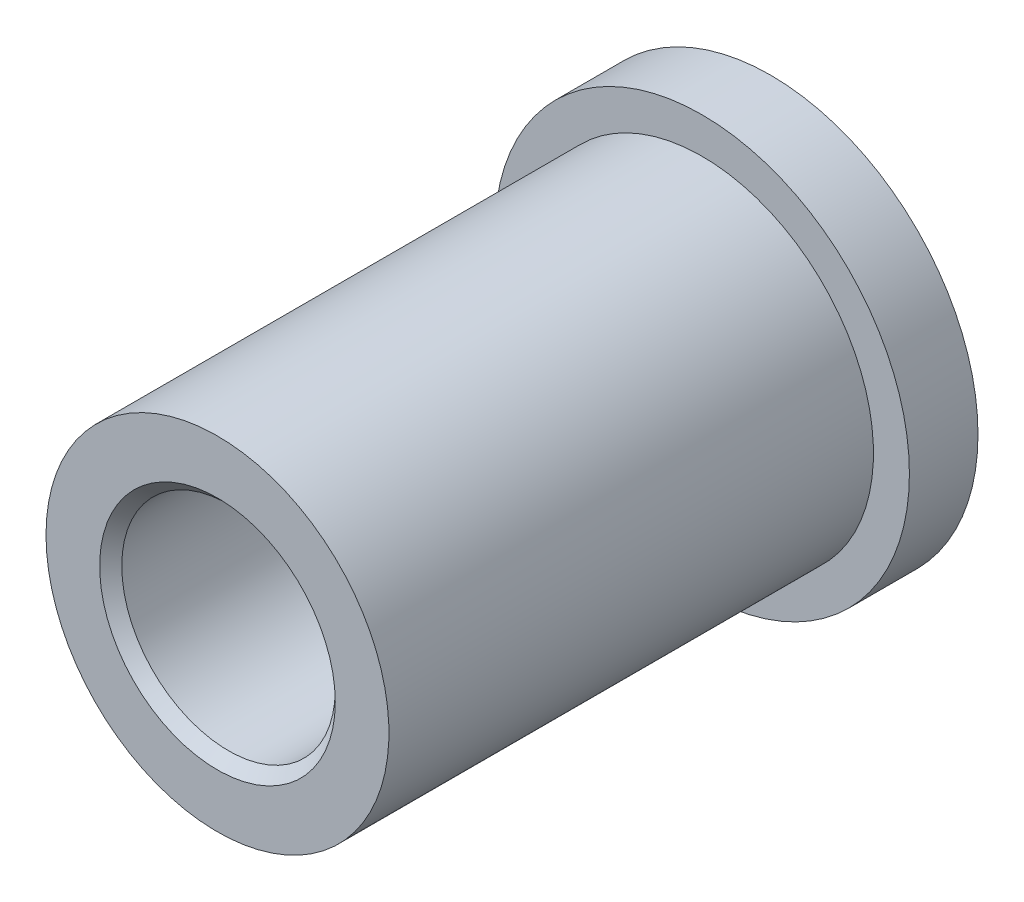
from build123d import *

# Parameters (mm, degrees)
CHAMFER1_SIZE = 0.254


with BuildPart() as part:
    # Sketch1 → Revolve1 (revolve)
    with BuildSketch(Plane(origin=(0, 0, 0), x_dir=(1, 0, 0), z_dir=(0, 1, 0))):
        Polygon((-1.4859, 11.1252), (-1.4859, 0), (0, 0), (0, 12.7), (-2.3114, 12.7), (-2.3114, 11.1252), align=None)
    revolve(axis=Axis((2.4511, 0, -12.7), (0, 0, 1)))

    # Chamfer1
    chamfer1_edges = [part.edges().sort_by_distance(p)[0] for p in [
        (4.9022, 0, -12.7),
        (4.9022, 0, 0),
    ]]
    chamfer(chamfer1_edges, length=CHAMFER1_SIZE)


solid = part.part
